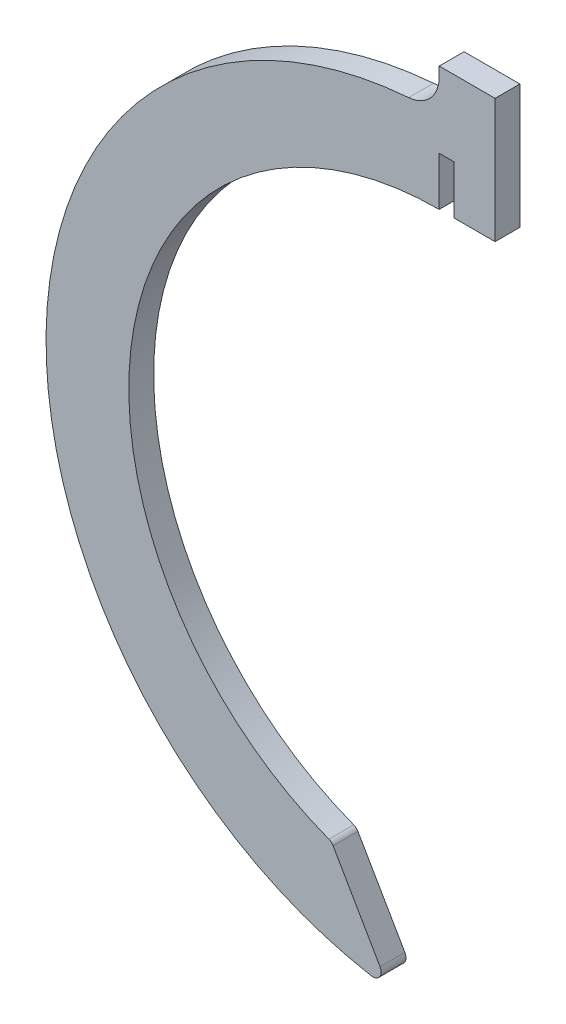
from build123d import *

# Parameters (mm, degrees)
BOSS_EXTRUDE1_DEPTH = 3
FILLET1_R           = 4
FILLET2_R           = 1
FILLET3_R           = 1


with BuildPart() as part:
    # Sketch1 → Boss-Extrude1 (new body)
    with BuildSketch(Plane.XY):
        with BuildLine():
            Line((0, 43.376726626), (0, 37.5))
            ThreePointArc((0, 37.5), (-36.914491769, 6.600780063), (-12.99543687, -35.176250803))
            Line((-12.99543687, -35.176250803), (-6.107994139, -47.105651546))
            ThreePointArc((-6.107994139, -47.105651546), (-47.401310364, 3.060355499), (0, 47.5))
            Line((0, 47.5), (0, 52.5))
            Line((0, 52.5), (6.75, 52.5))
            Line((6.75, 52.5), (6.75, 37.5))
            Line((6.75, 37.5), (1.79, 37.5))
            Line((1.79, 37.5), (1.79, 43.376726626))
            Line((1.79, 43.376726626), (0, 43.376726626))
        make_face()
    extrude(amount=BOSS_EXTRUDE1_DEPTH)

    # Fillet1
    fillet1_edges = [part.edges().sort_by_distance(p)[0] for p in [
        (0, 47.5, 1.5),
    ]]
    fillet(fillet1_edges, radius=FILLET1_R)

    # Fillet2
    fillet2_edges = [part.edges().sort_by_distance(p)[0] for p in [
        (-12.99543687, -35.176250803, 1.5),
    ]]
    fillet(fillet2_edges, radius=FILLET2_R)

    # Fillet3
    fillet3_edges = [part.edges().sort_by_distance(p)[0] for p in [
        (-6.107994139, -47.105651546, 1.5),
    ]]
    fillet(fillet3_edges, radius=FILLET3_R)


solid = part.part
